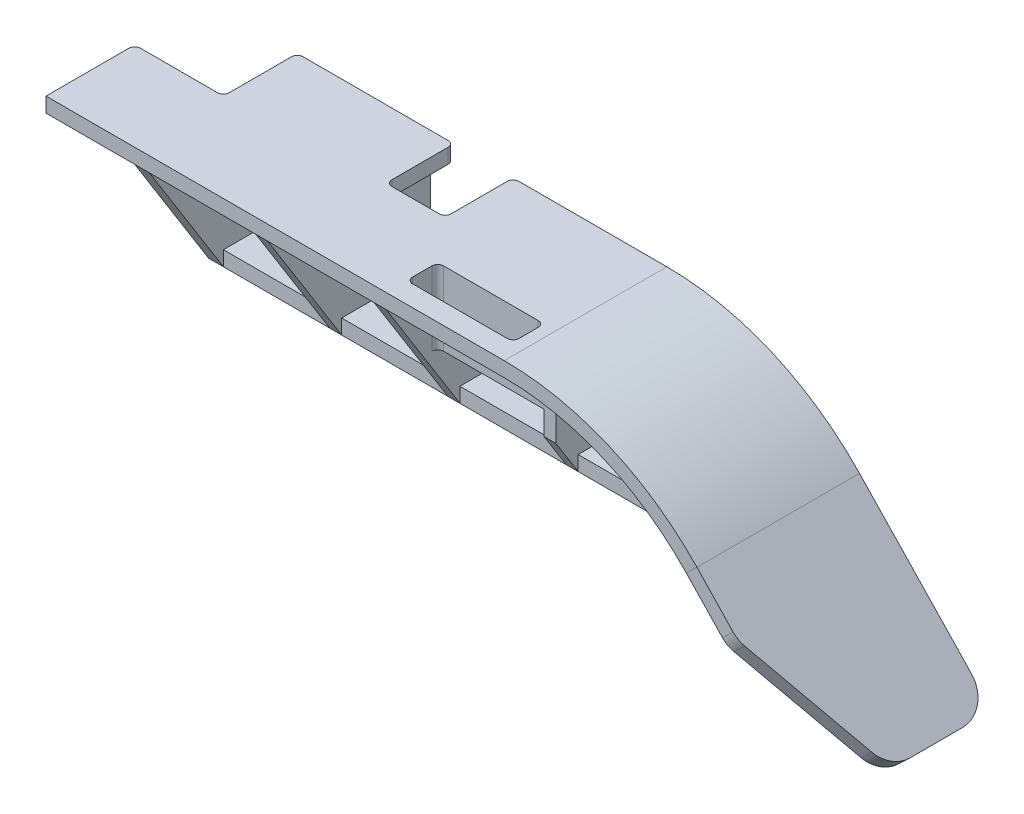
from build123d import *

# Parameters (mm, degrees)
SKETCH1_W            = 155
SKETCH1_H            = 55
BOSS_EXTRUDE1_DEPTH  = 5
SKETCH2_W            = 30
SKETCH2_H            = 25
CUT_EXTRUDE2_DEPTH   = 5
SKETCH3_W            = 5
SKETCH3_H            = 55
BOSS_EXTRUDE2_DEPTH  = 40
SKETCH10_W           = 55
SKETCH10_H           = 5
SKETCH14_W           = 125
SKETCH14_H           = 30
BOSS_EXTRUDE7_DEPTH  = 5
BOSS_EXTRUDE8_REACH  = 107
SKETCH16_W           = 30
SKETCH16_H           = 5
SKETCH19_W           = 4
SKETCH19_H           = 55
BOSS_EXTRUDE9_DEPTH  = 40
CUT_EXTRUDE4_DEPTH   = 125
SKETCH18_R           = 1.75
CUT_EXTRUDE5_DEPTH   = 5
SKETCH20_W           = 38
SKETCH20_H           = 16
CUT_EXTRUDE6_DEPTH   = 5
FILLET1_R            = 5
SKETCH21_W           = 5
SKETCH21_H           = 20
BOSS_EXTRUDE10_DEPTH = 36
CUT_EXTRUDE7_DEPTH   = 4
SKETCH23_W           = 36
SKETCH23_H           = 10.5
CUT_EXTRUDE8_DEPTH   = 5
FILLET2_R            = 2
SKETCH24_W           = 20
SKETCH24_H           = 23
CUT_EXTRUDE9_DEPTH   = 5
FILLET3_R            = 2
CHAMFER1_SIZE        = 45
CHAMFER1_SIZE2       = 20.983844617
FILLET4_R            = 10
FILLET5_R            = 10


with BuildPart() as part:
    # Sketch1 → Boss-Extrude1 (new body)
    with BuildSketch(Plane(origin=(0, 0, 0), x_dir=(1, 0, 0), z_dir=(0, 1, 0))):
        Rectangle(SKETCH1_W, SKETCH1_H)
    extrude(amount=BOSS_EXTRUDE1_DEPTH)

    # Sketch2 → Cut-Extrude2 (cut)
    with BuildSketch(Plane(origin=(0, 5, 0), x_dir=(1, 0, 0), z_dir=(0, 1, 0))):
        with Locations((-62.5, 15)):
            Rectangle(SKETCH2_W, SKETCH2_H)
    extrude(amount=-CUT_EXTRUDE2_DEPTH, mode=Mode.SUBTRACT)

    # Sketch3 → Boss-Extrude2 (add)
    with BuildSketch(Plane.XZ):
        with Locations((-45, 0)):
            Rectangle(SKETCH3_W, SKETCH3_H)
    extrude(amount=BOSS_EXTRUDE2_DEPTH)

    # Sweep1: sweep along a path in Sketch9
    with BuildLine(Plane.XY.offset(27.5)) as sweep1_path:
        Line((187.5, -70), (142.672413793, -22.931034483))
        ThreePointArc((142.672413793, -22.931034483), (112.952736872, -2.276947298), (77.5, 5))
    # Sketch10 → Sweep1 (sweep)
    with BuildSketch(Plane(origin=(77.5, 0, 0), x_dir=(0, 0, -1), z_dir=(1, 0, 0))):
        with Locations((0, 2.5)):
            Rectangle(SKETCH10_W, SKETCH10_H)
    sweep(path=sweep1_path.line)

    # Sketch14 → Boss-Extrude7 (add)
    with BuildSketch(Plane(origin=(0, -40, 0), x_dir=(1, 0, 0), z_dir=(0, 1, 0))):
        with Locations((20, 12.5)):
            Rectangle(SKETCH14_W, SKETCH14_H)
    extrude(amount=BOSS_EXTRUDE7_DEPTH)

    # Boss-Extrude8: up to this face of the body (flat: up to its plane)
    boss_extrude8_end = Plane(part.part.faces().sort_by_distance((161.465517241, -49.913793103, 0))[0])
    # Sketch16 → Boss-Extrude8 (add, up to the picked face)
    with BuildSketch(Plane(origin=(82.5, 0, 0), x_dir=(0, 0, -1), z_dir=(1, 0, 0)), mode=Mode.PRIVATE) as boss_extrude8_sk1:
        with Locations((12.5, -37.5)):
            Rectangle(SKETCH16_W, SKETCH16_H)
    boss_extrude8_tool1 = split(extrude(boss_extrude8_sk1.sketch, amount=BOSS_EXTRUDE8_REACH, mode=Mode.PRIVATE), bisect_by=boss_extrude8_end, keep=Keep.BOTH, mode=Mode.PRIVATE)
    add(boss_extrude8_tool1.solids().sort_by_distance((82.5, -37.5, -12.5))[0])

    # Sketch19 → Boss-Extrude9 (add)
    with BuildSketch(Plane.XZ):
        with Locations((75.5, 0)):
            Rectangle(SKETCH19_W, SKETCH19_H)
        with Locations((35.5, 0)):
            Rectangle(SKETCH19_W, SKETCH19_H)
        with Locations((-4.5, 0)):
            Rectangle(SKETCH19_W, SKETCH19_H)
    extrude(amount=BOSS_EXTRUDE9_DEPTH)

    # Sketch17 → Cut-Extrude4 (cut)
    with BuildSketch(Plane.ZY.offset(47.5)):
        Polygon((27.5, 0), (2.5, -40), (27.5, -40), align=None)
    extrude(amount=-CUT_EXTRUDE4_DEPTH, mode=Mode.SUBTRACT)

    # Sketch18 → Cut-Extrude5 (cut)
    with BuildSketch(Plane(origin=(0, -35, 0), x_dir=(1, 0, 0), z_dir=(0, 1, 0))):
        with Locations((-30.5, 17)):
            Circle(SKETCH18_R)
        with Locations((69.5, 17)):
            Circle(SKETCH18_R)
    extrude(amount=-CUT_EXTRUDE5_DEPTH, mode=Mode.SUBTRACT)

    # Sketch20 → Cut-Extrude6 (cut)
    with BuildSketch(Plane(origin=(0, -35, 0), x_dir=(1, 0, 0), z_dir=(0, 1, 0))):
        with Locations((100.5, 9.5)):
            Rectangle(SKETCH20_W, SKETCH20_H)
    extrude(amount=-CUT_EXTRUDE6_DEPTH, mode=Mode.SUBTRACT)

    # Fillet1
    fillet1_edges = [part.edges().sort_by_distance(p)[0] for p in [
        (81.5, -37.5, -1.5),
        (81.5, -37.5, -17.5),
        (119.5, -37.5, -17.5),
        (119.5, -37.5, -1.5),
    ]]
    fillet(fillet1_edges, radius=FILLET1_R)

    # Sketch21 → Boss-Extrude10 (add)
    with BuildSketch(Plane.ZY.offset(-73.5)):
        with Locations((7.5, -10)):
            Rectangle(SKETCH21_W, SKETCH21_H)
    extrude(amount=BOSS_EXTRUDE10_DEPTH)

    # Sketch22 → Cut-Extrude7 (cut)
    with BuildSketch(Plane.ZY.offset(-73.5)):
        Polygon((10, -28), (27.5, 0), (10, 0), align=None)
    extrude(amount=-CUT_EXTRUDE7_DEPTH, mode=Mode.SUBTRACT)

    # Sketch23 → Cut-Extrude8 (cut)
    with BuildSketch(Plane.XZ):
        with Locations((55.5, 15.25)):
            Rectangle(SKETCH23_W, SKETCH23_H)
    extrude(amount=-CUT_EXTRUDE8_DEPTH, mode=Mode.SUBTRACT)

    # Fillet2
    fillet2_edges = [part.edges().sort_by_distance(p)[0] for p in [
        (37.5, -7.5, 10),
        (73.5, 2.5, 10),
        (73.5, 2.5, 20.5),
        (37.5, 2.5, 20.5),
    ]]
    fillet(fillet2_edges, radius=FILLET2_R)

    # Sketch24 → Cut-Extrude9 (cut)
    with BuildSketch(Plane.XZ):
        with Locations((15.5, -16)):
            Rectangle(SKETCH24_W, SKETCH24_H)
    extrude(amount=-CUT_EXTRUDE9_DEPTH, mode=Mode.SUBTRACT)

    # Fillet3
    fillet3_edges = [part.edges().sort_by_distance(p)[0] for p in [
        (-77.5, 2.5, -2.5),
        (-47.5, -17.5, -27.5),
        (-47.5, 2.5, -2.5),
        (5.5, 2.5, -4.5),
        (5.5, 2.5, -27.5),
        (25.5, 2.5, -27.5),
        (25.5, 2.5, -4.5),
    ]]
    fillet(fillet3_edges, radius=FILLET3_R)

    # Chamfer1
    chamfer1_edges = [part.edges().sort_by_distance(p)[0] for p in [
        (185.689655172, -71.724137931, 27.5),
    ]]
    chamfer1_side = [part.faces().sort_by_distance(p)[0] for p in [
        (111.864070979, -4.817167716, 27.5),
    ]]
    chamfer(chamfer1_edges, length=CHAMFER1_SIZE, length2=CHAMFER1_SIZE2, reference=chamfer1_side[0])

    # Fillet4
    fillet4_edges = [part.edges().sort_by_distance(p)[0] for p in [
        (185.689655172, -71.724137931, 6.516155383),
        (154.655172414, -39.137931034, 27.5),
    ]]
    fillet(fillet4_edges, radius=FILLET4_R)

    # Fillet5
    fillet5_edges = [part.edges().sort_by_distance(p)[0] for p in [
        (185.689655172, -71.724137931, -27.5),
    ]]
    fillet(fillet5_edges, radius=FILLET5_R)


solid = part.part
